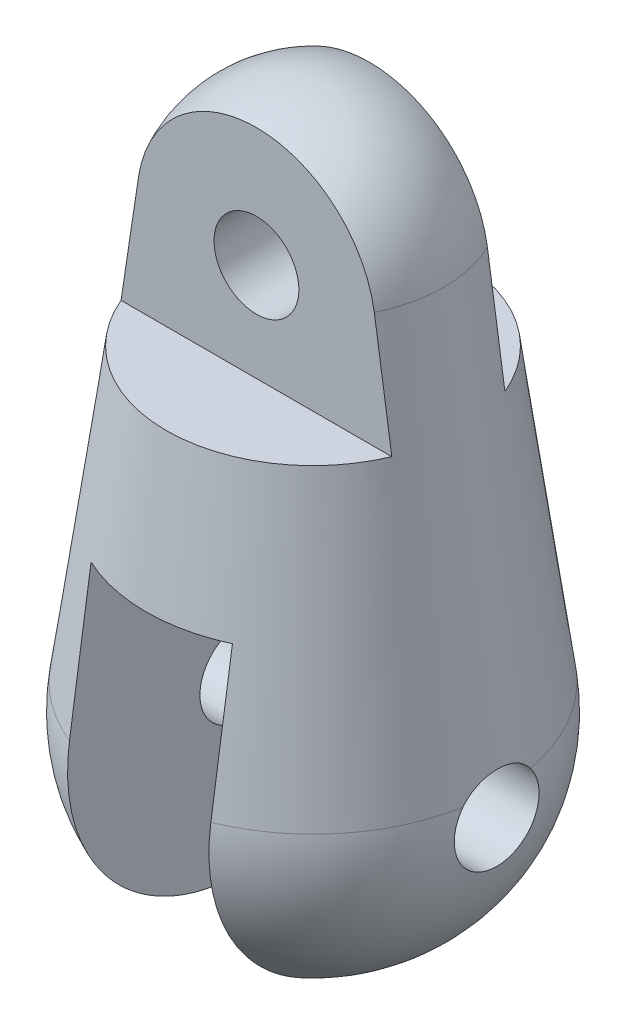
from build123d import *

# Parameters (mm, degrees)
SKETCH6_W               = 15
SKETCH6_H               = 38
CUT_EXTRUDE3_DEPTH      = 21
CUT_EXTRUDE3_DEPTH_BACK = 21
SKETCH10_W              = 17.380716029
SKETCH10_H              = 23.242829716
CUT_EXTRUDE4_DEPTH      = 21
CUT_EXTRUDE4_DEPTH_BACK = 21
SKETCH11_R              = 4.5
CUT_EXTRUDE5_DEPTH      = 13.540496218
CUT_EXTRUDE5_DEPTH_BACK = 25.540496218
SKETCH12_R              = 4.5
CUT_EXTRUDE6_DEPTH      = 21
CUT_EXTRUDE6_DEPTH_BACK = 21


with BuildPart() as part:
    # Sketch1 → Revolve1 (revolve)
    with BuildSketch(Plane.XY):
        with BuildLine():
            Line((-13.869223911, 45.909090909), (-19.813177016, 2.727272727))
            ThreePointArc((-19.813177016, 2.727272727), (-15.075567229, -13.142574813), (0, -20))
            Line((0, -20), (0, 58))
            ThreePointArc((0, 58), (-9.199802369, 54.55289706), (-13.869223911, 45.909090909))
        make_face()
    revolve(axis=Axis((0, 58, 0), (0, -1, 0)))

    # Sketch6 → Cut-Extrude3 (cut, two sides)
    with BuildSketch(Plane.XY) as cut_extrude3_sk:
        with Locations((0, -1)):
            Rectangle(SKETCH6_W, SKETCH6_H)
    extrude(amount=CUT_EXTRUDE3_DEPTH, mode=Mode.SUBTRACT)
    extrude(cut_extrude3_sk.sketch, amount=-CUT_EXTRUDE3_DEPTH_BACK, mode=Mode.SUBTRACT)

    # Sketch10 → Cut-Extrude4 (cut, two sides)
    with BuildSketch(Plane(origin=(0, 0, 0), x_dir=(0, 0, -1), z_dir=(1, 0, 0))) as cut_extrude4_sk:
        with Locations((-14.690358015, 45.212221832)):
            Rectangle(SKETCH10_W, SKETCH10_H)
        with Locations((14.690358015, 45.212221832)):
            Rectangle(SKETCH10_W, SKETCH10_H)
    extrude(amount=CUT_EXTRUDE4_DEPTH, mode=Mode.SUBTRACT)
    extrude(cut_extrude4_sk.sketch, amount=-CUT_EXTRUDE4_DEPTH_BACK, mode=Mode.SUBTRACT)

    # Sketch11 → Cut-Extrude5 (cut, two sides)
    with BuildSketch(Plane(origin=(0, 0, -6), x_dir=(-1, 0, 0), z_dir=(0, 0, -1))) as cut_extrude5_sk:
        with Locations((0, 44)):
            Circle(SKETCH11_R)
    extrude(amount=CUT_EXTRUDE5_DEPTH, mode=Mode.SUBTRACT)
    extrude(cut_extrude5_sk.sketch, amount=-CUT_EXTRUDE5_DEPTH_BACK, mode=Mode.SUBTRACT)

    # Sketch12 → Cut-Extrude6 (cut, two sides)
    with BuildSketch(Plane(origin=(0, 0, 0), x_dir=(0, 0, -1), z_dir=(1, 0, 0))) as cut_extrude6_sk:
        Circle(SKETCH12_R)
    extrude(amount=CUT_EXTRUDE6_DEPTH, mode=Mode.SUBTRACT)
    extrude(cut_extrude6_sk.sketch, amount=-CUT_EXTRUDE6_DEPTH_BACK, mode=Mode.SUBTRACT)


solid = part.part
